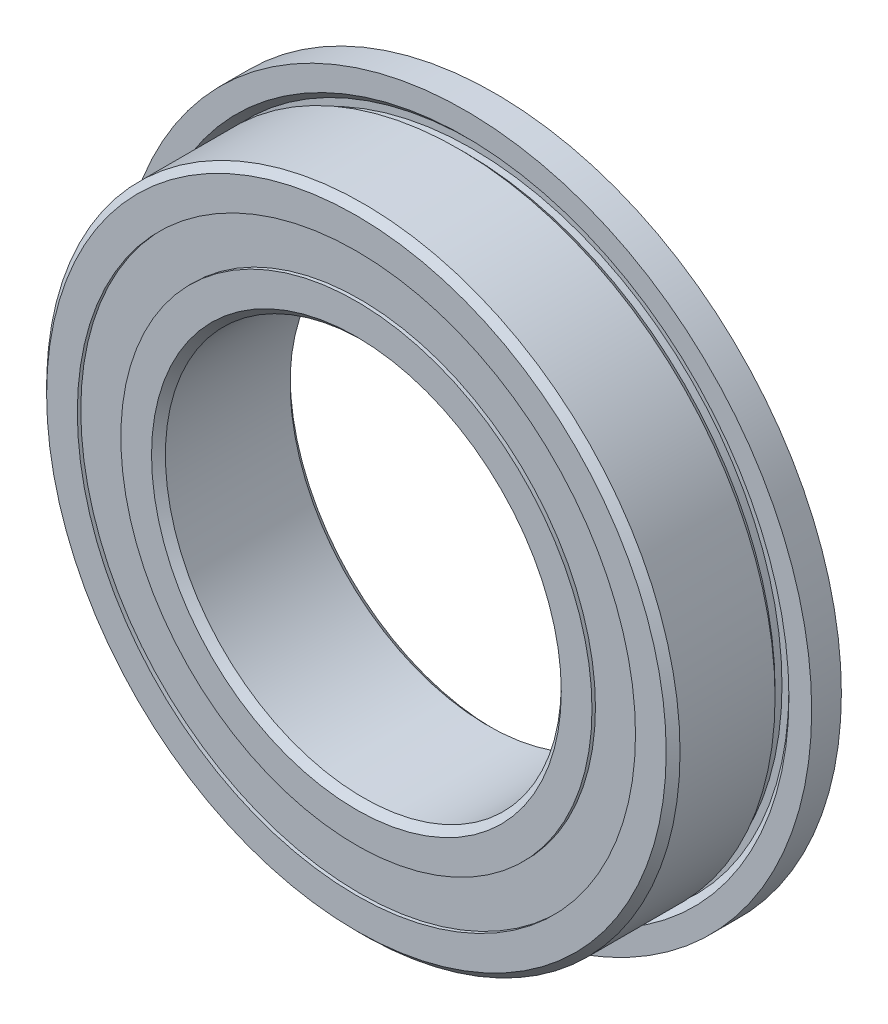
from build123d import *

# Parameters (mm, degrees)
SKETCH6_W         = 0.366300366
SKETCH6_H         = 1.098901098
CIRPATTERN1_COUNT = 13
SKETCH5_W         = 1.420443172
SKETCH5_H         = 2.197802198


with BuildPart() as part:
    # Sketch7 → Revolve7 (revolve)
    with BuildSketch(Plane(origin=(0, 0, 0), x_dir=(0, 0, -1), z_dir=(1, 0, 0))):
        with BuildLine():
            Line((3.5, 17.5), (2, 17.5))
            Line((2, 17.5), (2, 16.35))
            Line((2, 16.35), (2.35, 16))
            Line((2.35, 16), (2.35, 15.65))
            Line((2.35, 15.65), (2, 15.65))
            Line((2, 15.65), (1.65, 16))
            Line((1.65, 16), (-3.15, 16))
            Line((-3.15, 16), (-3.5, 15.65))
            Line((-3.5, 15.65), (-3.5, 14.098901099))
            Line((-3.5, 14.098901099), (-1.555555556, 14.098901099))
            ThreePointArc((-1.555555556, 14.098901099), (0, 14.904556828), (1.555555556, 14.098901099))
            Line((1.555555556, 14.098901099), (3.5, 14.098901099))
            Line((3.5, 14.098901099), (3.5, 15.65))
            Line((3.5, 15.65), (3.5, 17.5))
        make_face()
    revolve(axis=Axis((0, 0, 3.5), (0, 0, -1)))


with BuildPart() as body_2:
    # Sketch3 → Revolve3 (revolve)
    with BuildSketch(Plane(origin=(0, 0, 0), x_dir=(0, 0, -1), z_dir=(1, 0, 0))):
        with BuildLine():
            Line((-3.5, 11.901098901), (-1.555555556, 11.901098901))
            ThreePointArc((-1.555555556, 11.901098901), (0, 11.095443172), (1.555555556, 11.901098901))
            Line((1.555555556, 11.901098901), (3.5, 11.901098901))
            Line((3.5, 11.901098901), (3.5, 10.35))
            Line((3.5, 10.35), (3.15, 10))
            Line((3.15, 10), (-3.15, 10))
            Line((-3.15, 10), (-3.5, 10.35))
            Line((-3.5, 10.35), (-3.5, 11.901098901))
        make_face()
    revolve(axis=Axis((0, 0, 3.5), (0, 0, -1)))


with BuildPart() as body_3:
    # Sketch6 → Revolve6 (revolve)
    with BuildSketch(Plane(origin=(0, 0, 0), x_dir=(0, 0, -1), z_dir=(1, 0, 0))):
        with Locations((0, 13)):
            Rectangle(SKETCH6_W, SKETCH6_H)
    revolve(axis=Axis((0, 0, 3.5), (0, 0, -1)))


with BuildPart() as body_4:
    # Sketch4 → Revolve4 (revolve)
    with BuildSketch(Plane(origin=(0, 0, 0), x_dir=(0, 0, -1), z_dir=(1, 0, 0))):
        with BuildLine():
            Line((-1.904556828, 13), (1.904556828, 13))
            ThreePointArc((1.904556828, 13), (0, 14.904556828), (-1.904556828, 13))
        make_face()
    revolve(axis=Axis((0, 13, 1.904556828), (0, 0, -1)))


with BuildPart() as cirpattern1_1:
    # CirPattern1: pattern copy
    add(body_4.part.rotate(Axis((0, 0, -3.5), (0, 0, 1)), 1 * 360 / CIRPATTERN1_COUNT))


with BuildPart() as cirpattern1_2:
    # CirPattern1: pattern copy
    add(body_4.part.rotate(Axis((0, 0, -3.5), (0, 0, 1)), 2 * 360 / CIRPATTERN1_COUNT))


with BuildPart() as cirpattern1_3:
    # CirPattern1: pattern copy
    add(body_4.part.rotate(Axis((0, 0, -3.5), (0, 0, 1)), 3 * 360 / CIRPATTERN1_COUNT))


with BuildPart() as cirpattern1_4:
    # CirPattern1: pattern copy
    add(body_4.part.rotate(Axis((0, 0, -3.5), (0, 0, 1)), 4 * 360 / CIRPATTERN1_COUNT))


with BuildPart() as cirpattern1_5:
    # CirPattern1: pattern copy
    add(body_4.part.rotate(Axis((0, 0, -3.5), (0, 0, 1)), 5 * 360 / CIRPATTERN1_COUNT))


with BuildPart() as cirpattern1_6:
    # CirPattern1: pattern copy
    add(body_4.part.rotate(Axis((0, 0, -3.5), (0, 0, 1)), 6 * 360 / CIRPATTERN1_COUNT))


with BuildPart() as cirpattern1_7:
    # CirPattern1: pattern copy
    add(body_4.part.rotate(Axis((0, 0, -3.5), (0, 0, 1)), 7 * 360 / CIRPATTERN1_COUNT))


with BuildPart() as cirpattern1_8:
    # CirPattern1: pattern copy
    add(body_4.part.rotate(Axis((0, 0, -3.5), (0, 0, 1)), 8 * 360 / CIRPATTERN1_COUNT))


with BuildPart() as cirpattern1_9:
    # CirPattern1: pattern copy
    add(body_4.part.rotate(Axis((0, 0, -3.5), (0, 0, 1)), 9 * 360 / CIRPATTERN1_COUNT))


with BuildPart() as cirpattern1_10:
    # CirPattern1: pattern copy
    add(body_4.part.rotate(Axis((0, 0, -3.5), (0, 0, 1)), 10 * 360 / CIRPATTERN1_COUNT))


with BuildPart() as cirpattern1_11:
    # CirPattern1: pattern copy
    add(body_4.part.rotate(Axis((0, 0, -3.5), (0, 0, 1)), 11 * 360 / CIRPATTERN1_COUNT))


with BuildPart() as cirpattern1_12:
    # CirPattern1: pattern copy
    add(body_4.part.rotate(Axis((0, 0, -3.5), (0, 0, 1)), 12 * 360 / CIRPATTERN1_COUNT))


with BuildPart() as body_17:
    # Sketch5 → Revolve5 (revolve)
    with BuildSketch(Plane(origin=(0, 0, 0), x_dir=(0, 0, -1), z_dir=(1, 0, 0))):
        with Locations((-2.614778414, 13)):
            Rectangle(SKETCH5_W, SKETCH5_H)
        with Locations((2.614778414, 13)):
            Rectangle(SKETCH5_W, SKETCH5_H)
    revolve(axis=Axis((0, 0, 3.5), (0, 0, -1)))


solid = Compound([part.part, body_2.part, body_3.part, body_4.part, cirpattern1_1.part, cirpattern1_2.part, cirpattern1_3.part, cirpattern1_4.part, cirpattern1_5.part, cirpattern1_6.part, cirpattern1_7.part, cirpattern1_8.part, cirpattern1_9.part, cirpattern1_10.part, cirpattern1_11.part, cirpattern1_12.part, body_17.part])
